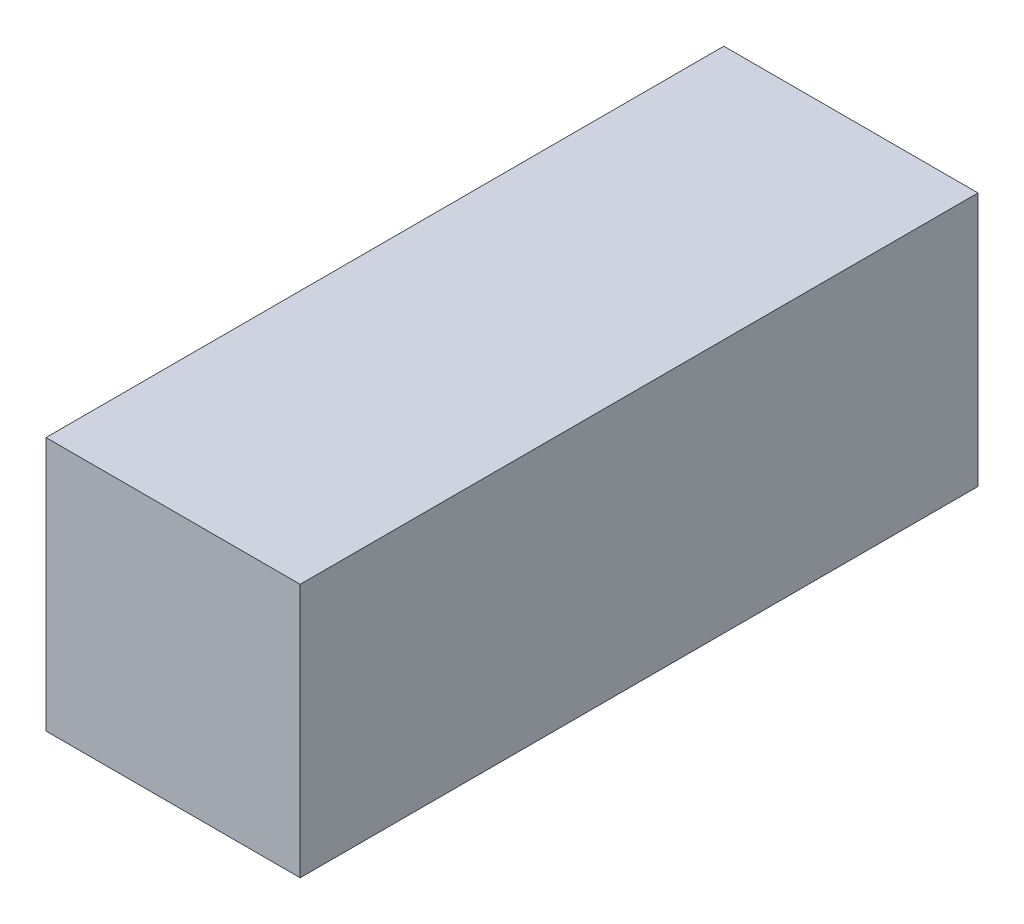
from build123d import *

# Parameters (mm, degrees)
SKETCH1_W           = 300
SKETCH1_H           = 300
BOSS_EXTRUDE1_DEPTH = 800


with BuildPart() as part:
    # Sketch1 → Boss-Extrude1 (new body)
    with BuildSketch(Plane.XY):
        with Locations((150, 150)):
            Rectangle(SKETCH1_W, SKETCH1_H)
    extrude(amount=BOSS_EXTRUDE1_DEPTH)


solid = part.part
